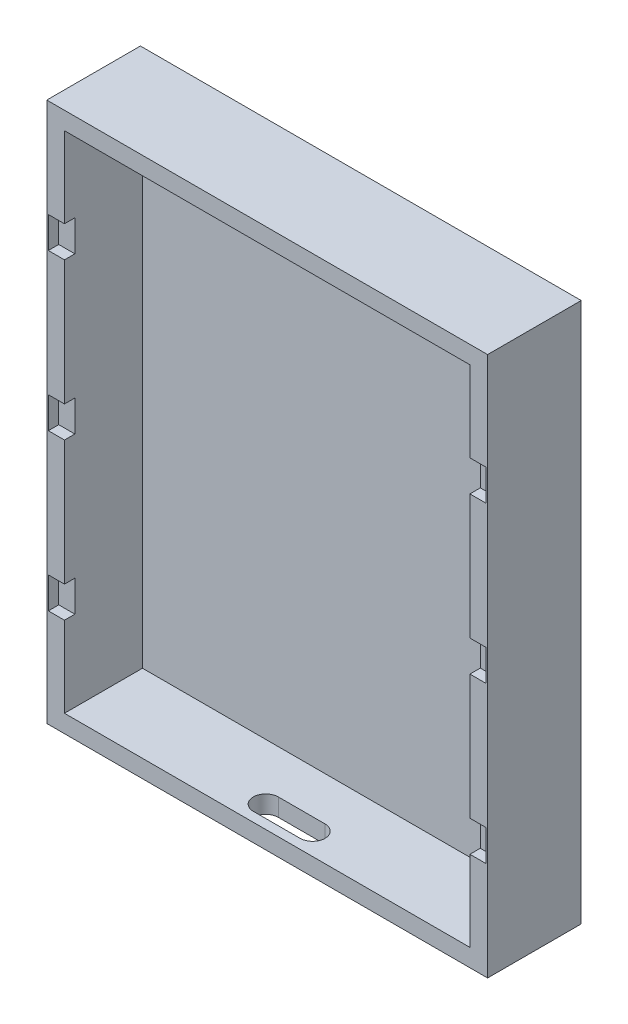
from build123d import *

# Parameters (mm, degrees)
MODEL_W             = 84.74935
MODEL_H             = 103.79946
MODEL_W_2           = 77.94935
MODEL_H_2           = 96.99946
EXTRUDE_2_DEPTH     = 15
SKETCH_1_W          = 84.74935
SKETCH_1_H          = 103.79946
EXTRUDE_3_DEPTH     = 3
SKETCH_2_W          = 3.1
SKETCH_2_H          = 6
CUT_EXTRUDE_1_DEPTH = 2
CUT_EXTRUDE_3_DEPTH = 10


with BuildPart() as part:
    # Model → 凸台-拉伸2 (new body)
    with BuildSketch(Plane.XY):
        with Locations((38.194325, 47.88337)):
            Rectangle(MODEL_W, MODEL_H)
        with Locations((38.194325, 47.88337)):
            Rectangle(MODEL_W_2, MODEL_H_2, mode=Mode.SUBTRACT)
    extrude(amount=EXTRUDE_2_DEPTH)

    # 草图1 → 凸台-拉伸3 (add)
    with BuildSketch(Plane(origin=(0, 0, 0), x_dir=(-1, 0, 0), z_dir=(0, 0, -1))):
        with Locations((-38.194325, 47.88337)):
            Rectangle(SKETCH_1_W, SKETCH_1_H)
    extrude(amount=EXTRUDE_3_DEPTH)

    # 草图2 → 切除-拉伸1 (cut)
    with BuildSketch(Plane.XY.offset(15)):
        with Locations((-2.33035, 77.88337)):
            Rectangle(SKETCH_2_W, SKETCH_2_H)
        with Locations((-2.33035, 47.88337)):
            Rectangle(SKETCH_2_W, SKETCH_2_H)
        with Locations((-2.33035, 17.88337)):
            Rectangle(SKETCH_2_W, SKETCH_2_H)
        with Locations((78.719, 17.88337)):
            Rectangle(SKETCH_2_W, SKETCH_2_H)
        with Locations((78.719, 47.88337)):
            Rectangle(SKETCH_2_W, SKETCH_2_H)
        with Locations((78.719, 77.88337)):
            Rectangle(SKETCH_2_W, SKETCH_2_H)
    extrude(amount=-CUT_EXTRUDE_1_DEPTH, mode=Mode.SUBTRACT)

    # 草图4 → 切除-拉伸3 (cut)
    with BuildSketch(Plane.XZ.offset(7.21636)):
        with BuildLine():
            Line((33.694325, 13.169990539), (42.694325, 13.169990539))
            ThreePointArc((42.694325, 13.169990539), (45.094325, 10.769990539), (42.694325, 8.369990539))
            Line((42.694325, 8.369990539), (33.694325, 8.369990539))
            ThreePointArc((33.694325, 8.369990539), (31.294325, 10.769990539), (33.694325, 13.169990539))
        make_face()
    extrude(amount=-CUT_EXTRUDE_3_DEPTH, mode=Mode.SUBTRACT)


solid = part.part
